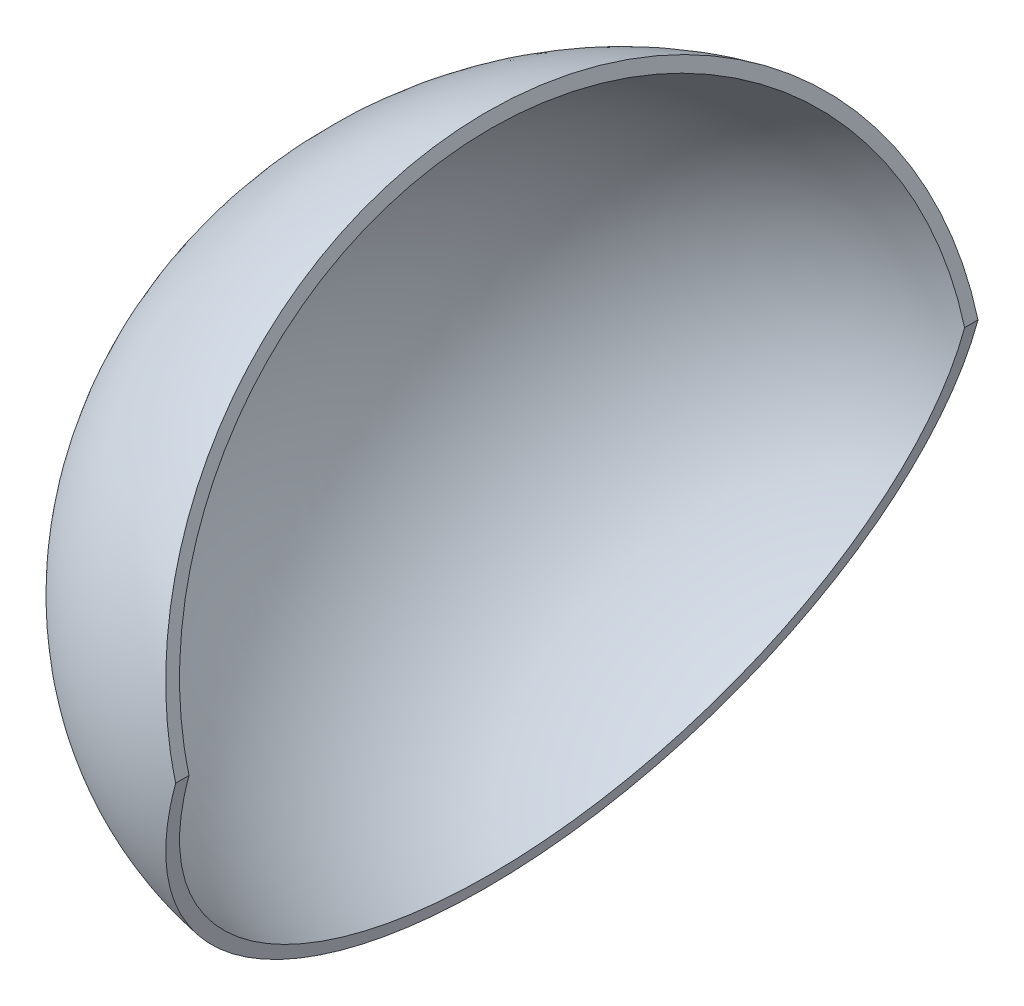
from build123d import *

# Parameters (mm, degrees)
REVOLVE2_ANGLE           = 75
REVOLVE2_OTHER_WAY_ANGLE = 75


with BuildPart() as part:
    # Sketch4 → Revolve2 (revolve)
    with BuildSketch(Plane(origin=(0, 0, 0), x_dir=(1, 0, 0), z_dir=(0, 1, 0))):
        with BuildLine():
            add(Edge.make_bspline(
                [(0, 14.5), (-1.627718152, 14.5), (-4.877775506, 13.754945412), (-9.041859421, 10.55010702), (-11.842048496, 5.719445199), (-12.828975752, 0), (-11.842048496, -5.719445199), (-9.041859421, -10.55010702), (-4.877775506, -13.754945412), (-1.627718152, -14.5), (0, -14.5)],
                knots=[0, 0, 0, 0, 0.392699082, 0.785398163, 1.178097245, 1.570796327, 1.963495408, 2.35619449, 2.748893572, 3.141592654, 3.141592654, 3.141592654, 3.141592654], degree=3))
            Line((0, -14.5), (0, -15))
            add(Edge.make_bspline(
                [(-10.583663309, 8.710282968), (-25.240396162, -15), (0, -15)],
                knots=[0.951225845, 0.951225845, 0.951225845, 3.141592654, 3.141592654, 3.141592654], degree=2, weights=[1, 0.457883429, 1]))
            add(Edge.make_bspline(
                [(0, 15), (-6.695615985, 15), (-10.583663309, 8.710282968)],
                knots=[3.141592654, 3.141592654, 3.141592654, 4.092818499, 4.092818499, 4.092818499], degree=2, weights=[1, 0.889012242, 1]))
            Line((0, 15), (0, 14.5))
        make_face()
    revolve(axis=Axis((0, 0, -15), (0, 0, 1)), revolution_arc=REVOLVE2_ANGLE)

    # Sketch4 → Revolve2 other way (revolve)
    with BuildSketch(Plane(origin=(0, 0, 0), x_dir=(1, 0, 0), z_dir=(0, 1, 0))):
        with BuildLine():
            add(Edge.make_bspline(
                [(0, 14.5), (-1.627718152, 14.5), (-4.877775506, 13.754945412), (-9.041859421, 10.55010702), (-11.842048496, 5.719445199), (-12.828975752, 0), (-11.842048496, -5.719445199), (-9.041859421, -10.55010702), (-4.877775506, -13.754945412), (-1.627718152, -14.5), (0, -14.5)],
                knots=[0, 0, 0, 0, 0.392699082, 0.785398163, 1.178097245, 1.570796327, 1.963495408, 2.35619449, 2.748893572, 3.141592654, 3.141592654, 3.141592654, 3.141592654], degree=3))
            Line((0, -14.5), (0, -15))
            add(Edge.make_bspline(
                [(-10.583663309, 8.710282968), (-25.240396162, -15), (0, -15)],
                knots=[0.951225845, 0.951225845, 0.951225845, 3.141592654, 3.141592654, 3.141592654], degree=2, weights=[1, 0.457883429, 1]))
            add(Edge.make_bspline(
                [(0, 15), (-6.695615985, 15), (-10.583663309, 8.710282968)],
                knots=[3.141592654, 3.141592654, 3.141592654, 4.092818499, 4.092818499, 4.092818499], degree=2, weights=[1, 0.889012242, 1]))
            Line((0, 15), (0, 14.5))
        make_face()
    revolve(axis=Axis((0, 0, -15), (0, 0, -1)), revolution_arc=REVOLVE2_OTHER_WAY_ANGLE)


solid = part.part
